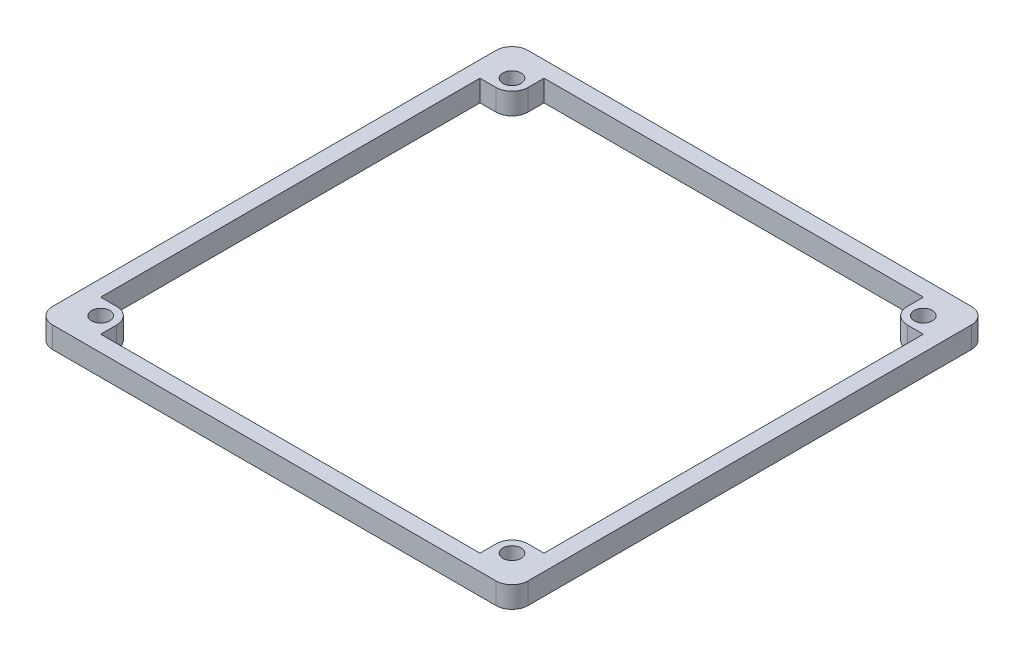
from build123d import *

# Parameters (mm, degrees)
SKETCH1_W           = 89
SKETCH1_H           = 89
SKETCH1_W_2         = 83
SKETCH1_H_2         = 83
BOSS_EXTRUDE1_DEPTH = 2
SKETCH4_W           = 6
SKETCH4_H           = 6
SKETCH4_R           = 1.7
BOSS_EXTRUDE3_DEPTH = 4
FILLET3_R           = 3
FILLET4_R           = 3


with BuildPart() as part:
    # Sketch1 → Boss-Extrude1 (new body, symmetric)
    with BuildSketch(Plane(origin=(0, 0, 0), x_dir=(1, 0, 0), z_dir=(0, 1, 0))):
        with Locations((44.5, 44.5)):
            Rectangle(SKETCH1_W, SKETCH1_H)
        with Locations((44.5, 44.5)):
            Rectangle(SKETCH1_W_2, SKETCH1_H_2, mode=Mode.SUBTRACT)
    extrude(amount=BOSS_EXTRUDE1_DEPTH, both=True)

    # Sketch4 → Boss-Extrude3 (add)
    with BuildSketch(Plane.XZ.offset(2)):
        with Locations((83, -6)):
            Rectangle(SKETCH4_W, SKETCH4_H)
        with Locations((83, -6)):
            Circle(SKETCH4_R, mode=Mode.SUBTRACT)
        with Locations((6, -6)):
            Rectangle(SKETCH4_W, SKETCH4_H)
        with Locations((6, -6)):
            Circle(SKETCH4_R, mode=Mode.SUBTRACT)
        with Locations((83, -83)):
            Rectangle(SKETCH4_W, SKETCH4_H)
        with Locations((83, -83)):
            Circle(SKETCH4_R, mode=Mode.SUBTRACT)
        with Locations((6, -83)):
            Rectangle(SKETCH4_W, SKETCH4_H)
        with Locations((6, -83)):
            Circle(SKETCH4_R, mode=Mode.SUBTRACT)
    extrude(amount=-BOSS_EXTRUDE3_DEPTH)

    # Fillet3
    fillet3_edges = [part.edges().sort_by_distance(p)[0] for p in [
        (9, 0, -9),
        (80, 0, -9),
        (9, 0, -80),
        (80, 0, -80),
    ]]
    fillet(fillet3_edges, radius=FILLET3_R)

    # Fillet4
    fillet4_edges = [part.edges().sort_by_distance(p)[0] for p in [
        (0, 0, -89),
        (89, 0, -89),
        (89, 0, 0),
        (0, 0, 0),
    ]]
    fillet(fillet4_edges, radius=FILLET4_R)


solid = part.part
